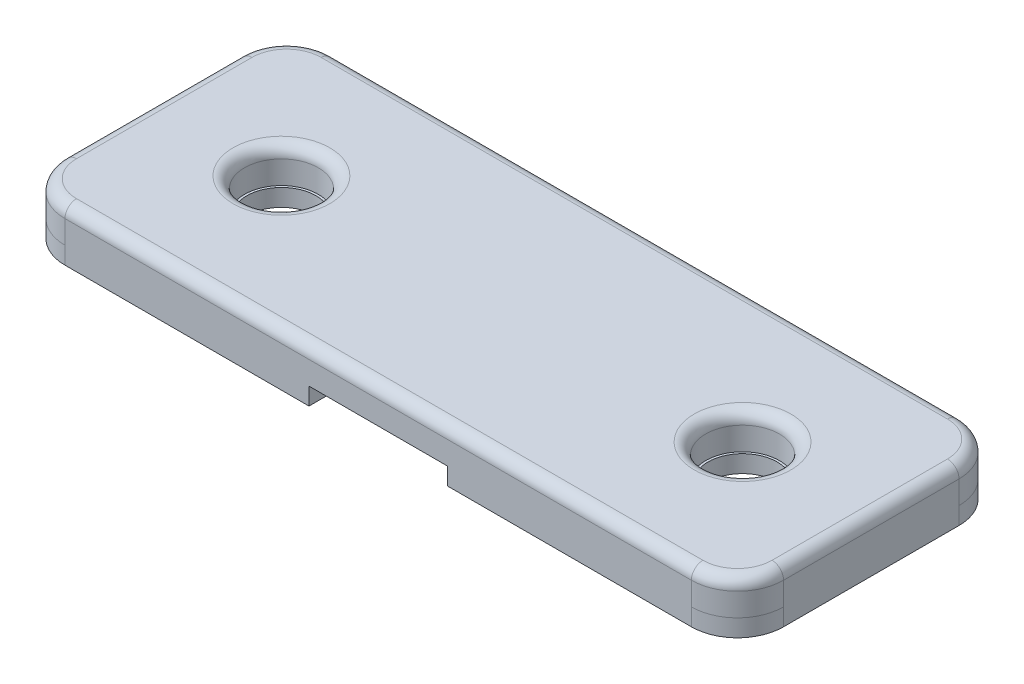
from build123d import *

# Parameters (mm, degrees)
SKETCH1_W           = 31.166722988
SKETCH1_H           = 11.608812618
SKETCH1_R           = 1.6
BOSS_EXTRUDE1_DEPTH = 1.5
FILLET1_R           = 2
SKETCH2_W           = 12.583361494
SKETCH2_H           = 11.608812618
SKETCH2_R           = 1.5
BOSS_EXTRUDE2_DEPTH = 0.75
FILLET2_R           = 2
FILLET3_R           = 0.5


with BuildPart() as part:
    # Sketch1 → Boss-Extrude1 (new body)
    with BuildSketch(Plane(origin=(0, 0, 0), x_dir=(1, 0, 0), z_dir=(0, 1, 0))):
        Rectangle(SKETCH1_W, SKETCH1_H)
        with Locations((-10, 0)):
            Circle(SKETCH1_R, mode=Mode.SUBTRACT)
        with Locations((10, 0)):
            Circle(SKETCH1_R, mode=Mode.SUBTRACT)
    extrude(amount=BOSS_EXTRUDE1_DEPTH)

    # Fillet1
    fillet1_edges = [part.edges().sort_by_distance(p)[0] for p in [
        (-15.583361494, 0.75, -5.804406309),
        (15.583361494, 0.75, -5.804406309),
        (15.583361494, 0.75, 5.804406309),
        (-15.583361494, 0.75, 5.804406309),
    ]]
    fillet(fillet1_edges, radius=FILLET1_R)

    # Sketch2 → Boss-Extrude2 (add)
    with BuildSketch(Plane(origin=(0, 0, 0), x_dir=(-1, 0, 0), z_dir=(0, -1, 0))):
        with Locations((9.291680747, 0)):
            Rectangle(SKETCH2_W, SKETCH2_H)
        with Locations((10, 0)):
            Circle(SKETCH2_R, mode=Mode.SUBTRACT)
        with Locations((-9.291680747, 0)):
            Rectangle(SKETCH2_W, SKETCH2_H)
        with Locations((-10, 0)):
            Circle(SKETCH2_R, mode=Mode.SUBTRACT)
    extrude(amount=BOSS_EXTRUDE2_DEPTH)

    # Fillet2
    fillet2_edges = [part.edges().sort_by_distance(p)[0] for p in [
        (-15.583361494, -0.375, 5.804406309),
        (-15.583361494, -0.375, -5.804406309),
        (15.583361494, -0.375, 5.804406309),
        (15.583361494, -0.375, -5.804406309),
    ]]
    fillet(fillet2_edges, radius=FILLET2_R)

    # Fillet3
    fillet3_edges = [part.edges().sort_by_distance(p)[0] for p in [
        (-11.6, 1.5, 0),
        (8.4, 1.5, 0),
        (-15.583361494, 1.5, 0),
        (0, 1.5, -5.804406309),
        (0, 1.5, 5.804406309),
        (15.583361494, 1.5, 0),
        (-14.997575056, 1.5, 5.218619872),
        (14.997575056, 1.5, 5.218619872),
        (14.997575056, 1.5, -5.218619872),
        (-14.997575056, 1.5, -5.218619872),
    ]]
    fillet(fillet3_edges, radius=FILLET3_R)


solid = part.part
